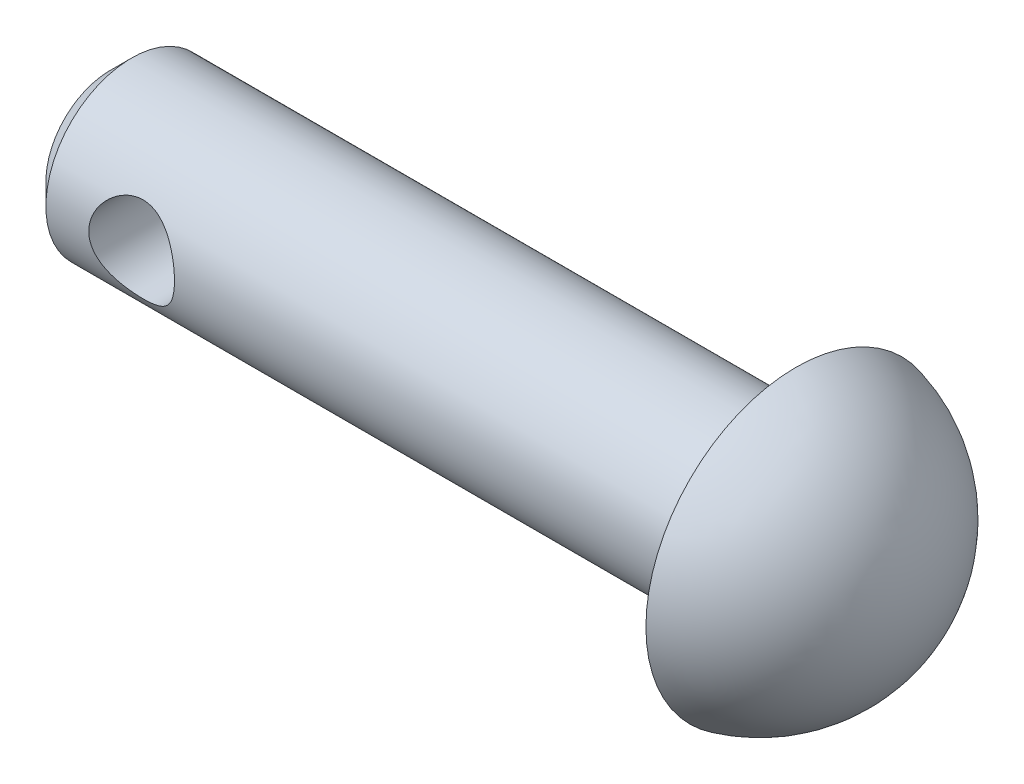
from build123d import *

# Parameters (mm, degrees)
SKETCH1_R               = 2
BOSS_EXTRUDE1_DEPTH     = 16
SKETCH2_R               = 1
CUT_EXTRUDE1_DEPTH      = 3
CUT_EXTRUDE1_DEPTH_BACK = 3
CHAMFER1_SIZE           = 0.5


with BuildPart() as part:
    # Sketch1 → Boss-Extrude1 (new body)
    with BuildSketch(Plane(origin=(0, 0, 0), x_dir=(0, 0, -1), z_dir=(1, 0, 0))):
        Circle(SKETCH1_R)
    extrude(amount=-BOSS_EXTRUDE1_DEPTH)

    # Sketch2 → Cut-Extrude1 (cut, two sides)
    with BuildSketch(Plane.XY) as cut_extrude1_sk:
        with Locations((-13.5, 0)):
            Circle(SKETCH2_R)
    extrude(amount=CUT_EXTRUDE1_DEPTH, mode=Mode.SUBTRACT)
    extrude(cut_extrude1_sk.sketch, amount=-CUT_EXTRUDE1_DEPTH_BACK, mode=Mode.SUBTRACT)

    # Sketch3 → Revolve1 (revolve)
    with BuildSketch(Plane(origin=(0, 0, 0), x_dir=(1, 0, 0), z_dir=(0, 1, 0))):
        with BuildLine():
            Line((2.757385023, 0), (0, 0))
            Line((0, 0), (0, 3.5))
            ThreePointArc((0, 3.5), (1.985229955, 2.227844932), (2.757385023, 0))
        make_face()
    revolve(axis=Axis((-5.097766842, 0, 0), (1, 0, 0)))

    # Chamfer1
    chamfer1_edges = [part.edges().sort_by_distance(p)[0] for p in [
        (-16, 0, 2),
    ]]
    chamfer(chamfer1_edges, length=CHAMFER1_SIZE)


solid = part.part
